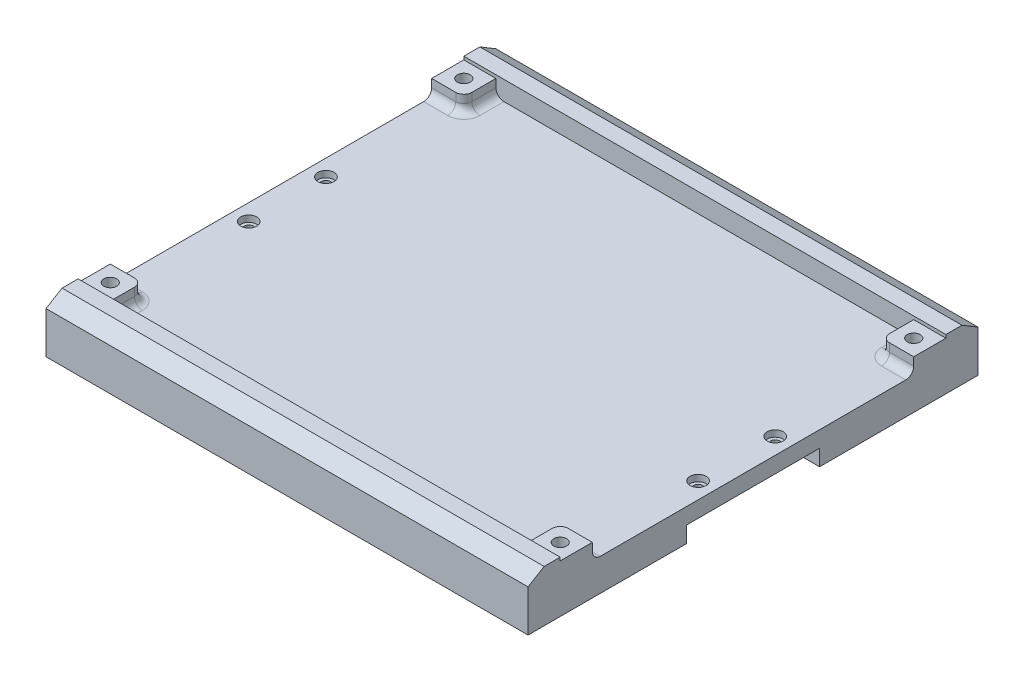
from build123d import *

# Parameters (mm, degrees)
SKETCH1_W           = 150
SKETCH1_H           = 140
BOSS_EXTRUDE1_DEPTH = 10
SKETCH2_W           = 10.4
SKETCH2_H           = 41.4
CUT_EXTRUDE1_DEPTH  = 5
BOSS_EXTRUDE2_DEPTH = 150
SKETCH4_W           = 150
SKETCH4_H           = 10
SKETCH4_R           = 2
BOSS_EXTRUDE3_DEPTH = 5
SKETCH5_R           = 2
CUT_EXTRUDE2_DEPTH  = 6
SKETCH6_R           = 1.5
CUT_EXTRUDE3_DEPTH  = 5
SKETCH7_R           = 2.5
CUT_EXTRUDE4_DEPTH  = 2
SKETCH8_W           = 130
SKETCH8_H           = 120
CUT_EXTRUDE5_DEPTH  = 5
FILLET1_R           = 2.5


with BuildPart() as part:
    # Sketch1 → Boss-Extrude1 (new body)
    with BuildSketch(Plane(origin=(0, 0, 0), x_dir=(1, 0, 0), z_dir=(0, 1, 0))):
        Rectangle(SKETCH1_W, SKETCH1_H)
    extrude(amount=BOSS_EXTRUDE1_DEPTH)

    # Sketch2 → Cut-Extrude1 (cut)
    with BuildSketch(Plane.XZ):
        with Locations((-69.9, 0)):
            Rectangle(SKETCH2_W, SKETCH2_H)
        with Locations((69.9, 0)):
            Rectangle(SKETCH2_W, SKETCH2_H)
    extrude(amount=-CUT_EXTRUDE1_DEPTH, mode=Mode.SUBTRACT)

    # Sketch3 → Boss-Extrude2 (add)
    with BuildSketch(Plane.ZY.offset(75)):
        Polygon((-70, 13), (-70, 10), (-60, 10), (-60, 16), (-65, 16), align=None)
        Polygon((70, 10), (70, 13), (65, 16), (60, 16), (60, 10), align=None)
    extrude(amount=-BOSS_EXTRUDE2_DEPTH)

    # Sketch4 → Boss-Extrude3 (add)
    with BuildSketch(Plane(origin=(0, 10, 0), x_dir=(1, 0, 0), z_dir=(0, 1, 0))):
        with Locations((0, 55)):
            Rectangle(SKETCH4_W, SKETCH4_H)
        with Locations((-70, 55)):
            Circle(SKETCH4_R, mode=Mode.SUBTRACT)
        with Locations((70, 55)):
            Circle(SKETCH4_R, mode=Mode.SUBTRACT)
        with Locations((0, -55)):
            Rectangle(SKETCH4_W, SKETCH4_H)
        with Locations((70, -55)):
            Circle(SKETCH4_R, mode=Mode.SUBTRACT)
        with Locations((-70, -55)):
            Circle(SKETCH4_R, mode=Mode.SUBTRACT)
    extrude(amount=BOSS_EXTRUDE3_DEPTH)

    # Sketch5 → Cut-Extrude2 (cut)
    with BuildSketch(Plane(origin=(0, 15, 0), x_dir=(1, 0, 0), z_dir=(0, 1, 0))):
        with Locations((-70, 55)):
            Circle(SKETCH5_R)
        with Locations((70, 55)):
            Circle(SKETCH5_R)
        with Locations((-70, -55)):
            Circle(SKETCH5_R)
        with Locations((70, -55)):
            Circle(SKETCH5_R)
    extrude(amount=-CUT_EXTRUDE2_DEPTH, mode=Mode.SUBTRACT)

    # Sketch6 → Cut-Extrude3 (cut)
    with BuildSketch(Plane(origin=(0, 5, 0), x_dir=(-1, 0, 0), z_dir=(0, -1, 0))):
        with Locations((69.899999566, -11.999895835)):
            Circle(SKETCH6_R)
        with Locations((69.899999566, 11.999895835)):
            Circle(SKETCH6_R)
        with Locations((-69.899999566, -11.999895835)):
            Circle(SKETCH6_R)
        with Locations((-69.899999566, 11.999895835)):
            Circle(SKETCH6_R)
    extrude(amount=-CUT_EXTRUDE3_DEPTH, mode=Mode.SUBTRACT)

    # Sketch7 → Cut-Extrude4 (cut)
    with BuildSketch(Plane(origin=(0, 10, 0), x_dir=(1, 0, 0), z_dir=(0, 1, 0))):
        with Locations((-69.899999566, 11.999895835)):
            Circle(SKETCH7_R)
        with Locations((-69.899999566, -11.999895835)):
            Circle(SKETCH7_R)
        with Locations((69.899999566, -11.999895835)):
            Circle(SKETCH7_R)
        with Locations((69.899999566, 11.999895835)):
            Circle(SKETCH7_R)
    extrude(amount=-CUT_EXTRUDE4_DEPTH, mode=Mode.SUBTRACT)

    # Sketch8 → Cut-Extrude5 (cut)
    with BuildSketch(Plane(origin=(0, 15, 0), x_dir=(1, 0, 0), z_dir=(0, 1, 0))):
        Rectangle(SKETCH8_W, SKETCH8_H)
    extrude(amount=-CUT_EXTRUDE5_DEPTH, mode=Mode.SUBTRACT)

    # Fillet1
    fillet1_edges = [part.edges().sort_by_distance(p)[0] for p in [
        (-70, 10, 50),
        (70, 10, 50),
        (70, 10, -50),
        (65, 12.5, -50),
        (65, 10, -55),
        (65, 12.5, 50),
        (-65, 10, -55),
        (-65, 12.5, -50),
        (-65, 12.5, 50),
        (65, 10, 55),
        (-65, 10, 55),
        (-70, 10, -50),
    ]]
    fillet(fillet1_edges, radius=FILLET1_R)


solid = part.part
